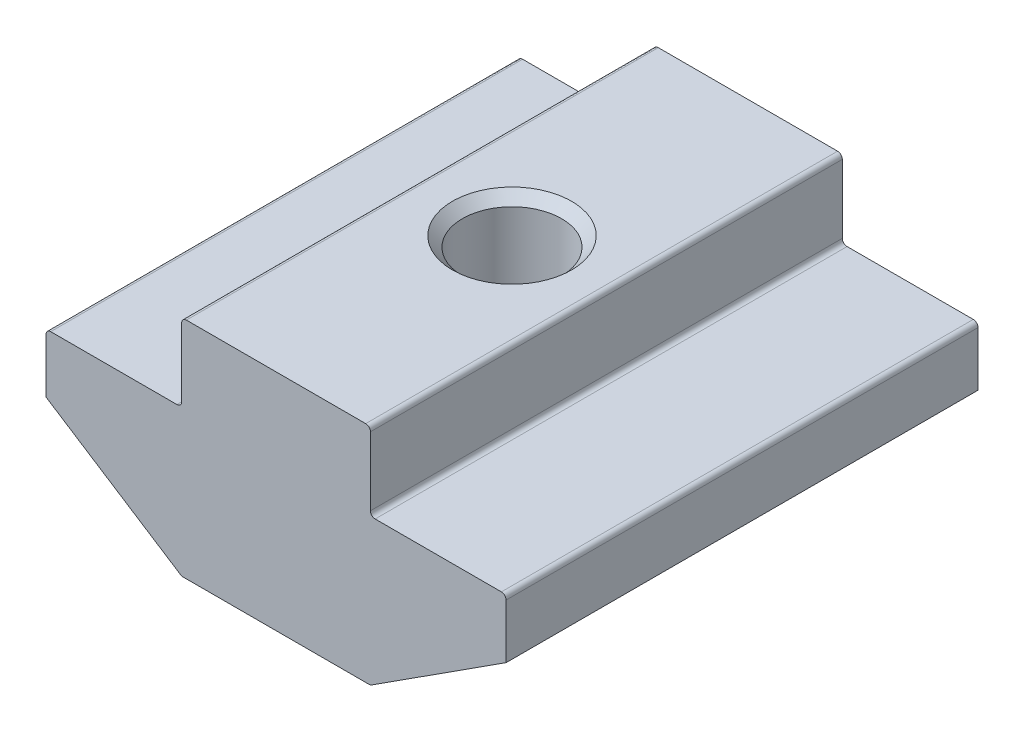
from build123d import *

# Parameters (mm, degrees)
EXTRUDE_1_DEPTH = 10
FILLET_1_R      = 0.2


with BuildPart() as part:
    # Эскиз1 → Бобышка-Вытянуть1 (new body, symmetric)
    with BuildSketch(Plane.XY):
        Polygon((4, 0), (-4, 0), (-4, -3.3), (-9.75, -3.3), (-9.75, -5.8), (-4, -9.5), (4, -9.5), (9.75, -5.8), (9.75, -3.3), (4, -3.3), align=None)
    extrude(amount=EXTRUDE_1_DEPTH, both=True)

    # Эскиз4 → Отверстие обработанное метчиком M53 (revolve, cut)
    with BuildSketch(Plane(origin=(0, 0, 0), x_dir=(0, 0, 1), z_dir=(1, 0, 0))):
        Polygon((0, 0), (0, 9.5), (2.525, 9.5), (2.1, 9.075), (2.1, 0.425), (2.525, 0), align=None)
    revolve(axis=Axis((0, 6.35, 0), (0, -1, 0)), mode=Mode.SUBTRACT)

    # Скругление1
    fillet_1_edges = [part.edges().sort_by_distance(p)[0] for p in [
        (-4, 0, 0),
        (4, 0, 0),
        (4, -3.3, 0),
        (9.75, -3.3, 0),
        (4, -9.5, 0),
        (-4, -9.5, 0),
        (-9.75, -3.3, 0),
        (-4, -3.3, 0),
    ]]
    fillet(fillet_1_edges, radius=FILLET_1_R)


solid = part.part
